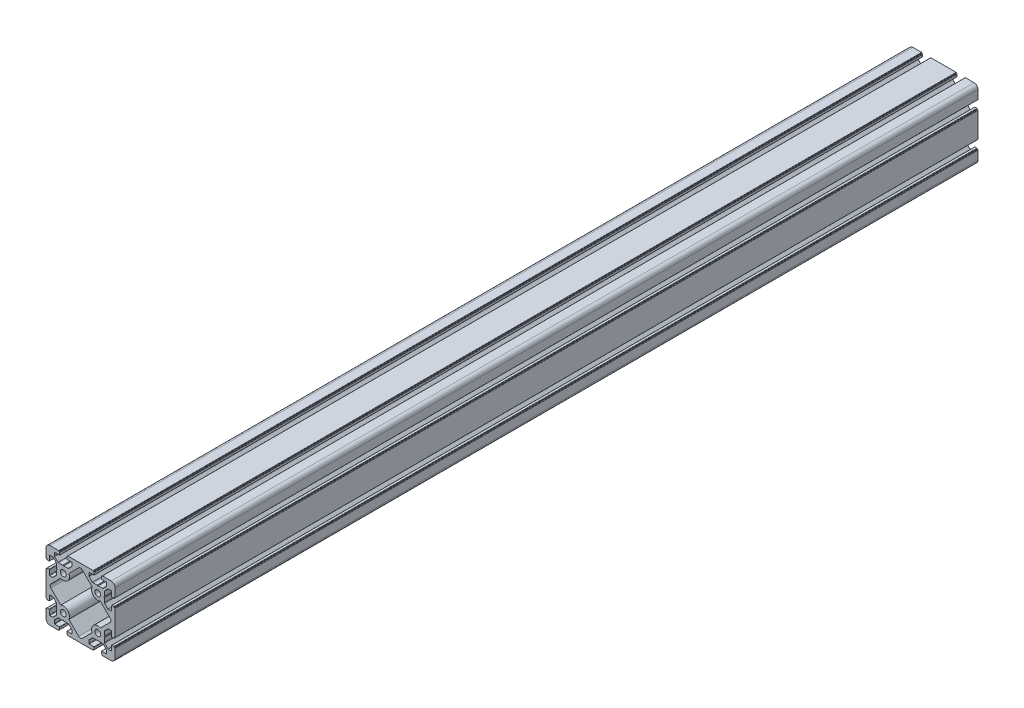
from build123d import *

# Parameters (mm, degrees)
SKETCH_1_R      = 3.4
EXTRUDE_1_DEPTH = 1000


with BuildPart() as part:
    # Эскиз1 → Бобышка-Вытянуть1 (new body)
    with BuildSketch(Plane.XY):
        with BuildLine():
            Line((-40, 30.25), (-40, 35.5))
            ThreePointArc((-40, 35.5), (-38.681980515, 38.681980515), (-35.5, 40))
            Line((-35.5, 40), (-30.25, 40))
            Line((-30.25, 40), (-25.4, 40))
            ThreePointArc((-25.4, 40), (-25.187867966, 39.912132034), (-25.1, 39.7))
            Line((-25.1, 39.7), (-25.1, 39))
            Line((-25.1, 39), (-24.4, 39))
            ThreePointArc((-24.4, 39), (-24.187867966, 38.912132034), (-24.1, 38.7))
            Line((-24.1, 38.7), (-24.1, 36.3))
            ThreePointArc((-24.1, 36.3), (-24.187867966, 36.087867966), (-24.4, 36))
            Line((-24.4, 36), (-29.95, 36))
            ThreePointArc((-29.95, 36), (-30.162132034, 35.912132034), (-30.25, 35.7))
            Line((-30.25, 35.7), (-30.25, 32.364213562))
            ThreePointArc((-30.25, 32.364213562), (-30.173879533, 31.98153013), (-29.957106781, 31.657106781))
            Line((-29.957106781, 31.657106781), (-26.292893219, 27.992893219))
            ThreePointArc((-26.292893219, 27.992893219), (-25.96846987, 27.776120467), (-25.585786438, 27.7))
            Line((-25.585786438, 27.7), (-20.6, 27.7))
            Line((-20.6, 27.7), (-20, 27.1))
            Line((-20, 27.1), (-19.4, 27.7))
            Line((-19.4, 27.7), (-14.414213562, 27.7))
            ThreePointArc((-14.414213562, 27.7), (-14.03153013, 27.776120467), (-13.707106781, 27.992893219))
            Line((-13.707106781, 27.992893219), (-10.042893219, 31.657106781))
            ThreePointArc((-10.042893219, 31.657106781), (-9.826120467, 31.98153013), (-9.75, 32.364213562))
            Line((-9.75, 32.364213562), (-9.75, 35.7))
            ThreePointArc((-9.75, 35.7), (-9.837867966, 35.912132034), (-10.05, 36))
            Line((-10.05, 36), (-15.6, 36))
            ThreePointArc((-15.6, 36), (-15.812132034, 36.087867966), (-15.9, 36.3))
            Line((-15.9, 36.3), (-15.9, 38.7))
            ThreePointArc((-15.9, 38.7), (-15.812132034, 38.912132034), (-15.6, 39))
            Line((-15.6, 39), (-14.9, 39))
            Line((-14.9, 39), (-14.9, 39.7))
            ThreePointArc((-14.9, 39.7), (-14.812132034, 39.912132034), (-14.6, 40))
            Line((-14.6, 40), (-9.75, 40))
            Line((-9.75, 40), (9.75, 40))
            Line((9.75, 40), (14.6, 40))
            ThreePointArc((14.6, 40), (14.812132034, 39.912132034), (14.9, 39.7))
            Line((14.9, 39.7), (14.9, 39))
            Line((14.9, 39), (15.6, 39))
            ThreePointArc((15.6, 39), (15.812132034, 38.912132034), (15.9, 38.7))
            Line((15.9, 38.7), (15.9, 36.3))
            ThreePointArc((15.9, 36.3), (15.812132034, 36.087867966), (15.6, 36))
            Line((15.6, 36), (10.05, 36))
            ThreePointArc((10.05, 36), (9.837867966, 35.912132034), (9.75, 35.7))
            Line((9.75, 35.7), (9.75, 32.364213562))
            ThreePointArc((9.75, 32.364213562), (9.826120467, 31.98153013), (10.042893219, 31.657106781))
            Line((10.042893219, 31.657106781), (13.707106781, 27.992893219))
            ThreePointArc((13.707106781, 27.992893219), (14.03153013, 27.776120467), (14.414213562, 27.7))
            Line((14.414213562, 27.7), (19.4, 27.7))
            Line((19.4, 27.7), (20, 27.1))
            Line((20, 27.1), (20.6, 27.7))
            Line((20.6, 27.7), (25.585786438, 27.7))
            ThreePointArc((25.585786438, 27.7), (25.96846987, 27.776120467), (26.292893219, 27.992893219))
            Line((26.292893219, 27.992893219), (29.957106781, 31.657106781))
            ThreePointArc((29.957106781, 31.657106781), (30.173879533, 31.98153013), (30.25, 32.364213562))
            Line((30.25, 32.364213562), (30.25, 35.7))
            ThreePointArc((30.25, 35.7), (30.162132034, 35.912132034), (29.95, 36))
            Line((29.95, 36), (24.4, 36))
            ThreePointArc((24.4, 36), (24.187867966, 36.087867966), (24.1, 36.3))
            Line((24.1, 36.3), (24.1, 38.7))
            ThreePointArc((24.1, 38.7), (24.187867966, 38.912132034), (24.4, 39))
            Line((24.4, 39), (25.1, 39))
            Line((25.1, 39), (25.1, 39.7))
            ThreePointArc((25.1, 39.7), (25.187867966, 39.912132034), (25.4, 40))
            Line((25.4, 40), (30.25, 40))
            Line((30.25, 40), (35.5, 40))
            ThreePointArc((35.5, 40), (38.681980515, 38.681980515), (40, 35.5))
            Line((40, 35.5), (40, 30.25))
            Line((40, 30.25), (40, 25.4))
            ThreePointArc((40, 25.4), (39.912132034, 25.187867966), (39.7, 25.1))
            Line((39.7, 25.1), (39, 25.1))
            Line((39, 25.1), (39, 24.4))
            ThreePointArc((39, 24.4), (38.912132034, 24.187867966), (38.7, 24.1))
            Line((38.7, 24.1), (36.3, 24.1))
            ThreePointArc((36.3, 24.1), (36.087867966, 24.187867966), (36, 24.4))
            Line((36, 24.4), (36, 29.95))
            ThreePointArc((36, 29.95), (35.912132034, 30.162132034), (35.7, 30.25))
            Line((35.7, 30.25), (32.364213562, 30.25))
            ThreePointArc((32.364213562, 30.25), (31.98153013, 30.173879533), (31.657106781, 29.957106781))
            Line((31.657106781, 29.957106781), (27.992893219, 26.292893219))
            ThreePointArc((27.992893219, 26.292893219), (27.776120467, 25.96846987), (27.7, 25.585786438))
            Line((27.7, 25.585786438), (27.7, 20.6))
            Line((27.7, 20.6), (27.1, 20))
            Line((27.1, 20), (27.7, 19.4))
            Line((27.7, 19.4), (27.7, 14.414213562))
            ThreePointArc((27.7, 14.414213562), (27.776120467, 14.03153013), (27.992893219, 13.707106781))
            Line((27.992893219, 13.707106781), (31.657106781, 10.042893219))
            ThreePointArc((31.657106781, 10.042893219), (31.98153013, 9.826120467), (32.364213562, 9.75))
            Line((32.364213562, 9.75), (35.7, 9.75))
            ThreePointArc((35.7, 9.75), (35.912132034, 9.837867966), (36, 10.05))
            Line((36, 10.05), (36, 15.6))
            ThreePointArc((36, 15.6), (36.087867966, 15.812132034), (36.3, 15.9))
            Line((36.3, 15.9), (38.7, 15.9))
            ThreePointArc((38.7, 15.9), (38.912132034, 15.812132034), (39, 15.6))
            Line((39, 15.6), (39, 14.9))
            Line((39, 14.9), (39.7, 14.9))
            ThreePointArc((39.7, 14.9), (39.912132034, 14.812132034), (40, 14.6))
            Line((40, 14.6), (40, 9.75))
            Line((40, 9.75), (40, -9.75))
            Line((40, -9.75), (40, -14.6))
            ThreePointArc((40, -14.6), (39.912132034, -14.812132034), (39.7, -14.9))
            Line((39.7, -14.9), (39, -14.9))
            Line((39, -14.9), (39, -15.6))
            ThreePointArc((39, -15.6), (38.912132034, -15.812132034), (38.7, -15.9))
            Line((38.7, -15.9), (36.3, -15.9))
            ThreePointArc((36.3, -15.9), (36.087867966, -15.812132034), (36, -15.6))
            Line((36, -15.6), (36, -10.05))
            ThreePointArc((36, -10.05), (35.912132034, -9.837867966), (35.7, -9.75))
            Line((35.7, -9.75), (32.364213562, -9.75))
            ThreePointArc((32.364213562, -9.75), (31.98153013, -9.826120467), (31.657106781, -10.042893219))
            Line((31.657106781, -10.042893219), (27.992893219, -13.707106781))
            ThreePointArc((27.992893219, -13.707106781), (27.776120467, -14.03153013), (27.7, -14.414213562))
            Line((27.7, -14.414213562), (27.7, -19.4))
            Line((27.7, -19.4), (27.1, -20))
            Line((27.1, -20), (27.7, -20.6))
            Line((27.7, -20.6), (27.7, -25.585786438))
            ThreePointArc((27.7, -25.585786438), (27.776120467, -25.96846987), (27.992893219, -26.292893219))
            Line((27.992893219, -26.292893219), (31.657106781, -29.957106781))
            ThreePointArc((31.657106781, -29.957106781), (31.98153013, -30.173879533), (32.364213562, -30.25))
            Line((32.364213562, -30.25), (35.7, -30.25))
            ThreePointArc((35.7, -30.25), (35.912132034, -30.162132034), (36, -29.95))
            Line((36, -29.95), (36, -24.4))
            ThreePointArc((36, -24.4), (36.087867966, -24.187867966), (36.3, -24.1))
            Line((36.3, -24.1), (38.7, -24.1))
            ThreePointArc((38.7, -24.1), (38.912132034, -24.187867966), (39, -24.4))
            Line((39, -24.4), (39, -25.1))
            Line((39, -25.1), (39.7, -25.1))
            ThreePointArc((39.7, -25.1), (39.912132034, -25.187867966), (40, -25.4))
            Line((40, -25.4), (40, -30.25))
            Line((40, -30.25), (40, -35.5))
            ThreePointArc((40, -35.5), (38.681980515, -38.681980515), (35.5, -40))
            Line((35.5, -40), (30.25, -40))
            Line((30.25, -40), (25.4, -40))
            ThreePointArc((25.4, -40), (25.187867966, -39.912132034), (25.1, -39.7))
            Line((25.1, -39.7), (25.1, -39))
            Line((25.1, -39), (24.4, -39))
            ThreePointArc((24.4, -39), (24.187867966, -38.912132034), (24.1, -38.7))
            Line((24.1, -38.7), (24.1, -36.3))
            ThreePointArc((24.1, -36.3), (24.187867966, -36.087867966), (24.4, -36))
            Line((24.4, -36), (29.95, -36))
            ThreePointArc((29.95, -36), (30.162132034, -35.912132034), (30.25, -35.7))
            Line((30.25, -35.7), (30.25, -32.364213562))
            ThreePointArc((30.25, -32.364213562), (30.173879533, -31.98153013), (29.957106781, -31.657106781))
            Line((29.957106781, -31.657106781), (26.292893219, -27.992893219))
            ThreePointArc((26.292893219, -27.992893219), (25.96846987, -27.776120467), (25.585786438, -27.7))
            Line((25.585786438, -27.7), (20.6, -27.7))
            Line((20.6, -27.7), (20, -27.1))
            Line((20, -27.1), (19.4, -27.7))
            Line((19.4, -27.7), (14.414213562, -27.7))
            ThreePointArc((14.414213562, -27.7), (14.03153013, -27.776120467), (13.707106781, -27.992893219))
            Line((13.707106781, -27.992893219), (10.042893219, -31.657106781))
            ThreePointArc((10.042893219, -31.657106781), (9.826120467, -31.98153013), (9.75, -32.364213562))
            Line((9.75, -32.364213562), (9.75, -35.7))
            ThreePointArc((9.75, -35.7), (9.837867966, -35.912132034), (10.05, -36))
            Line((10.05, -36), (15.6, -36))
            ThreePointArc((15.6, -36), (15.812132034, -36.087867966), (15.9, -36.3))
            Line((15.9, -36.3), (15.9, -38.7))
            ThreePointArc((15.9, -38.7), (15.812132034, -38.912132034), (15.6, -39))
            Line((15.6, -39), (14.9, -39))
            Line((14.9, -39), (14.9, -39.7))
            ThreePointArc((14.9, -39.7), (14.812132034, -39.912132034), (14.6, -40))
            Line((14.6, -40), (9.75, -40))
            Line((9.75, -40), (-9.75, -40))
            Line((-9.75, -40), (-14.6, -40))
            ThreePointArc((-14.6, -40), (-14.812132034, -39.912132034), (-14.9, -39.7))
            Line((-14.9, -39.7), (-14.9, -39))
            Line((-14.9, -39), (-15.6, -39))
            ThreePointArc((-15.6, -39), (-15.812132034, -38.912132034), (-15.9, -38.7))
            Line((-15.9, -38.7), (-15.9, -36.3))
            ThreePointArc((-15.9, -36.3), (-15.812132034, -36.087867966), (-15.6, -36))
            Line((-15.6, -36), (-10.05, -36))
            ThreePointArc((-10.05, -36), (-9.837867966, -35.912132034), (-9.75, -35.7))
            Line((-9.75, -35.7), (-9.75, -32.364213562))
            ThreePointArc((-9.75, -32.364213562), (-9.826120467, -31.98153013), (-10.042893219, -31.657106781))
            Line((-10.042893219, -31.657106781), (-13.707106781, -27.992893219))
            ThreePointArc((-13.707106781, -27.992893219), (-14.03153013, -27.776120467), (-14.414213562, -27.7))
            Line((-14.414213562, -27.7), (-19.4, -27.7))
            Line((-19.4, -27.7), (-20, -27.1))
            Line((-20, -27.1), (-20.6, -27.7))
            Line((-20.6, -27.7), (-25.585786438, -27.7))
            ThreePointArc((-25.585786438, -27.7), (-25.96846987, -27.776120467), (-26.292893219, -27.992893219))
            Line((-26.292893219, -27.992893219), (-29.957106781, -31.657106781))
            ThreePointArc((-29.957106781, -31.657106781), (-30.173879533, -31.98153013), (-30.25, -32.364213562))
            Line((-30.25, -32.364213562), (-30.25, -35.7))
            ThreePointArc((-30.25, -35.7), (-30.162132034, -35.912132034), (-29.95, -36))
            Line((-29.95, -36), (-24.4, -36))
            ThreePointArc((-24.4, -36), (-24.187867966, -36.087867966), (-24.1, -36.3))
            Line((-24.1, -36.3), (-24.1, -38.7))
            ThreePointArc((-24.1, -38.7), (-24.187867966, -38.912132034), (-24.4, -39))
            Line((-24.4, -39), (-25.1, -39))
            Line((-25.1, -39), (-25.1, -39.7))
            ThreePointArc((-25.1, -39.7), (-25.187867966, -39.912132034), (-25.4, -40))
            Line((-25.4, -40), (-30.25, -40))
            Line((-30.25, -40), (-35.5, -40))
            ThreePointArc((-35.5, -40), (-38.681980515, -38.681980515), (-40, -35.5))
            Line((-40, -35.5), (-40, -30.25))
            Line((-40, -30.25), (-40, -25.4))
            ThreePointArc((-40, -25.4), (-39.912132034, -25.187867966), (-39.7, -25.1))
            Line((-39.7, -25.1), (-39, -25.1))
            Line((-39, -25.1), (-39, -24.4))
            ThreePointArc((-39, -24.4), (-38.912132034, -24.187867966), (-38.7, -24.1))
            Line((-38.7, -24.1), (-36.3, -24.1))
            ThreePointArc((-36.3, -24.1), (-36.087867966, -24.187867966), (-36, -24.4))
            Line((-36, -24.4), (-36, -29.95))
            ThreePointArc((-36, -29.95), (-35.912132034, -30.162132034), (-35.7, -30.25))
            Line((-35.7, -30.25), (-32.364213562, -30.25))
            ThreePointArc((-32.364213562, -30.25), (-31.98153013, -30.173879533), (-31.657106781, -29.957106781))
            Line((-31.657106781, -29.957106781), (-27.992893219, -26.292893219))
            ThreePointArc((-27.992893219, -26.292893219), (-27.776120467, -25.96846987), (-27.7, -25.585786438))
            Line((-27.7, -25.585786438), (-27.7, -20.6))
            Line((-27.7, -20.6), (-27.1, -20))
            Line((-27.1, -20), (-27.7, -19.4))
            Line((-27.7, -19.4), (-27.7, -14.414213562))
            ThreePointArc((-27.7, -14.414213562), (-27.776120467, -14.03153013), (-27.992893219, -13.707106781))
            Line((-27.992893219, -13.707106781), (-31.657106781, -10.042893219))
            ThreePointArc((-31.657106781, -10.042893219), (-31.98153013, -9.826120467), (-32.364213562, -9.75))
            Line((-32.364213562, -9.75), (-35.7, -9.75))
            ThreePointArc((-35.7, -9.75), (-35.912132034, -9.837867966), (-36, -10.05))
            Line((-36, -10.05), (-36, -15.6))
            ThreePointArc((-36, -15.6), (-36.087867966, -15.812132034), (-36.3, -15.9))
            Line((-36.3, -15.9), (-38.7, -15.9))
            ThreePointArc((-38.7, -15.9), (-38.912132034, -15.812132034), (-39, -15.6))
            Line((-39, -15.6), (-39, -14.9))
            Line((-39, -14.9), (-39.7, -14.9))
            ThreePointArc((-39.7, -14.9), (-39.912132034, -14.812132034), (-40, -14.6))
            Line((-40, -14.6), (-40, -9.75))
            Line((-40, -9.75), (-40, 9.75))
            Line((-40, 9.75), (-40, 14.6))
            ThreePointArc((-40, 14.6), (-39.912132034, 14.812132034), (-39.7, 14.9))
            Line((-39.7, 14.9), (-39, 14.9))
            Line((-39, 14.9), (-39, 15.6))
            ThreePointArc((-39, 15.6), (-38.912132034, 15.812132034), (-38.7, 15.9))
            Line((-38.7, 15.9), (-36.3, 15.9))
            ThreePointArc((-36.3, 15.9), (-36.087867966, 15.812132034), (-36, 15.6))
            Line((-36, 15.6), (-36, 10.05))
            ThreePointArc((-36, 10.05), (-35.912132034, 9.837867966), (-35.7, 9.75))
            Line((-35.7, 9.75), (-32.364213562, 9.75))
            ThreePointArc((-32.364213562, 9.75), (-31.98153013, 9.826120467), (-31.657106781, 10.042893219))
            Line((-31.657106781, 10.042893219), (-27.992893219, 13.707106781))
            ThreePointArc((-27.992893219, 13.707106781), (-27.776120467, 14.03153013), (-27.7, 14.414213562))
            Line((-27.7, 14.414213562), (-27.7, 19.4))
            Line((-27.7, 19.4), (-27.1, 20))
            Line((-27.1, 20), (-27.7, 20.6))
            Line((-27.7, 20.6), (-27.7, 25.585786438))
            ThreePointArc((-27.7, 25.585786438), (-27.776120467, 25.96846987), (-27.992893219, 26.292893219))
            Line((-27.992893219, 26.292893219), (-31.657106781, 29.957106781))
            ThreePointArc((-31.657106781, 29.957106781), (-31.98153013, 30.173879533), (-32.364213562, 30.25))
            Line((-32.364213562, 30.25), (-35.7, 30.25))
            ThreePointArc((-35.7, 30.25), (-35.912132034, 30.162132034), (-36, 29.95))
            Line((-36, 29.95), (-36, 24.4))
            ThreePointArc((-36, 24.4), (-36.087867966, 24.187867966), (-36.3, 24.1))
            Line((-36.3, 24.1), (-38.7, 24.1))
            ThreePointArc((-38.7, 24.1), (-38.912132034, 24.187867966), (-39, 24.4))
            Line((-39, 24.4), (-39, 25.1))
            Line((-39, 25.1), (-39.7, 25.1))
            ThreePointArc((-39.7, 25.1), (-39.912132034, 25.187867966), (-40, 25.4))
            Line((-40, 25.4), (-40, 30.25))
        make_face()
        with Locations((-20, 20)):
            Circle(SKETCH_1_R, mode=Mode.SUBTRACT)
        with Locations((20, 20)):
            Circle(SKETCH_1_R, mode=Mode.SUBTRACT)
        with Locations((20, -20)):
            Circle(SKETCH_1_R, mode=Mode.SUBTRACT)
        with Locations((-20, -20)):
            Circle(SKETCH_1_R, mode=Mode.SUBTRACT)
        with BuildLine():
            Line((-13.464840731, 23.021869178), (-2.121320344, 34.365389566))
            ThreePointArc((-2.121320344, 34.365389566), (0, 35.244069222), (2.121320344, 34.365389566))
            Line((2.121320344, 34.365389566), (13.464840731, 23.021869178))
            ThreePointArc((13.464840731, 23.021869178), (14.908831175, 14.908831175), (23.021869178, 13.464840731))
            Line((23.021869178, 13.464840731), (34.365389566, 2.121320344))
            ThreePointArc((34.365389566, 2.121320344), (35.244069222, 0), (34.365389566, -2.121320344))
            Line((34.365389566, -2.121320344), (23.021869178, -13.464840731))
            ThreePointArc((23.021869178, -13.464840731), (14.908831175, -14.908831175), (13.464840731, -23.021869178))
            Line((13.464840731, -23.021869178), (2.121320344, -34.365389566))
            ThreePointArc((2.121320344, -34.365389566), (0, -35.244069222), (-2.121320344, -34.365389566))
            Line((-2.121320344, -34.365389566), (-13.464840731, -23.021869178))
            ThreePointArc((-13.464840731, -23.021869178), (-14.908831175, -14.908831175), (-23.021869178, -13.464840731))
            Line((-23.021869178, -13.464840731), (-34.365389566, -2.121320344))
            ThreePointArc((-34.365389566, -2.121320344), (-35.244069222, 0), (-34.365389566, 2.121320344))
            Line((-34.365389566, 2.121320344), (-23.021869178, 13.464840731))
            ThreePointArc((-23.021869178, 13.464840731), (-14.908831175, 14.908831175), (-13.464840731, 23.021869178))
        make_face(mode=Mode.SUBTRACT)
    extrude(amount=EXTRUDE_1_DEPTH)


solid = part.part
